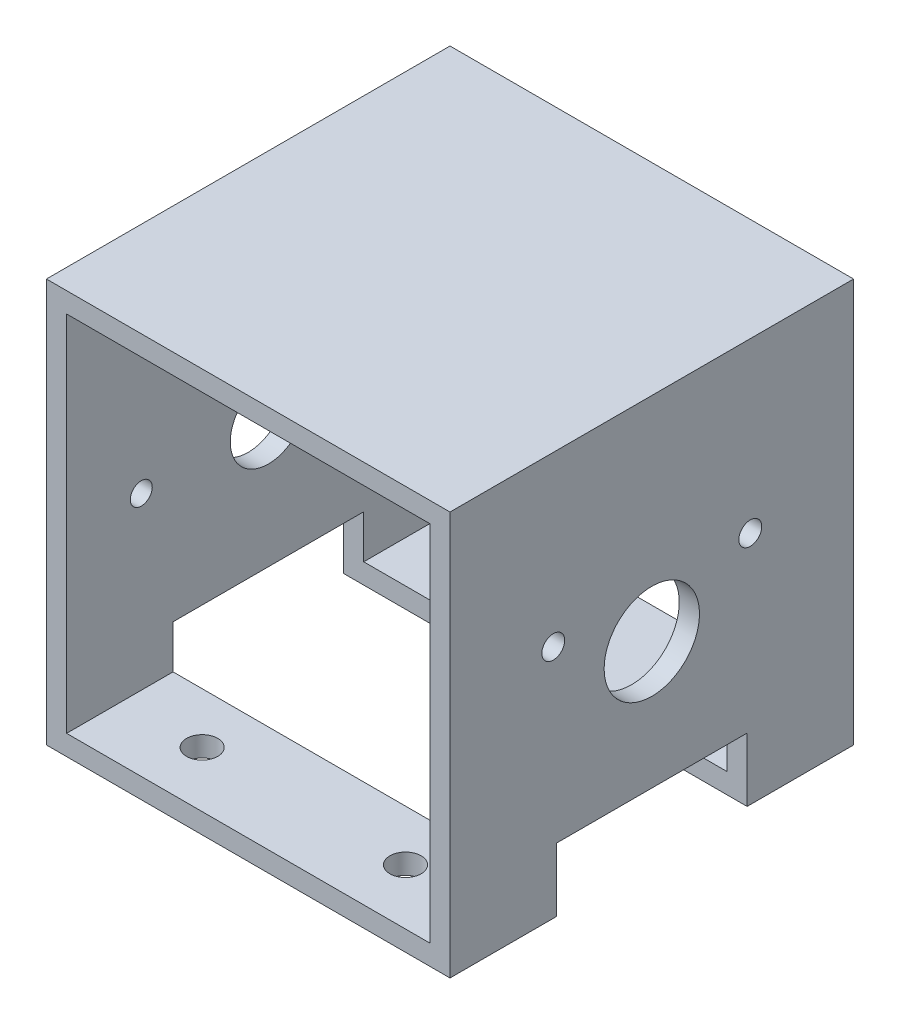
from build123d import *

# Parameters (mm, degrees)
SKETCH1_W                 = 63.5
SKETCH1_H                 = 63.5
SKETCH1_W_2               = 57.15
SKETCH1_H_2               = 57.15
EXTRUDE_THIN1_DEPTH       = 63.5
SKETCH2_W                 = 30
SKETCH2_H                 = 20
CUT_EXTRUDE1_DEPTH        = 64.5
SKETCH5_R                 = 7.5
CUT_EXTRUDE3_DEPTH        = 4.175
M3_CLEARANCE_HOLE1_D      = 3.6
M3_CLEARANCE_HOLE1_DEPTH  = 3.175
F_8_32_TAPPED_HOLE1_D     = 3.4544
F_8_32_TAPPED_HOLE1_DEPTH = 3.175
CUT_EXTRUDE4_REACH        = 65.5
SKETCH13_R                = 6
F_8_CLEARANCE_HOLE1_D     = 4.9149
F_8_CLEARANCE_HOLE1_DEPTH = 3.175


with BuildPart() as part:
    # Sketch1 → Extrude-Thin1 (new body)
    with BuildSketch(Plane.XY):
        Rectangle(SKETCH1_W, SKETCH1_H)
        Rectangle(SKETCH1_W_2, SKETCH1_H_2, mode=Mode.SUBTRACT)
    extrude(amount=EXTRUDE_THIN1_DEPTH)

    # Sketch2 → Cut-Extrude1 (cut, through all)
    with BuildSketch(Plane(origin=(31.75, 0, 0), x_dir=(0, 0, -1), z_dir=(1, 0, 0))):
        with Locations((-31.75, -31.75)):
            Rectangle(SKETCH2_W, SKETCH2_H)
    extrude(amount=-CUT_EXTRUDE1_DEPTH, mode=Mode.SUBTRACT)

    # Sketch5 → Cut-Extrude3 (cut, through all)
    with BuildSketch(Plane(origin=(28.575, 11.830115966, 29.988402314), x_dir=(0, 0, 1), z_dir=(-1, 0, 0))):
        with Locations((1.761597686, -13.580115966)):
            Circle(SKETCH5_R)
    extrude(amount=-CUT_EXTRUDE3_DEPTH, mode=Mode.SUBTRACT)

    # M3 Clearance Hole1
    with Locations(Plane(origin=(28.575, 11.830115966, 29.988402314), x_dir=(0, 0, 1), z_dir=(-1, 0, 0))):
        with Locations((-13.738402314, -6.580115966), (17.261597686, -6.580115966)):
            Hole(M3_CLEARANCE_HOLE1_D / 2, depth=M3_CLEARANCE_HOLE1_DEPTH)

    # #8-32 Tapped Hole1
    with Locations(Plane.ZY.offset(31.75)):
        with Locations((51.75, -1.75), (11.75, -1.75)):
            Hole(F_8_32_TAPPED_HOLE1_D / 2, depth=F_8_32_TAPPED_HOLE1_DEPTH)

    # Sketch13 → Cut-Extrude4 (cut, up to next)
    with BuildSketch(Plane.ZY.offset(31.75), mode=Mode.PRIVATE) as cut_extrude4_sk1:
        with Locations((31.75, -1.75)):
            Circle(SKETCH13_R)
    cut_extrude4_tool1 = extrude(cut_extrude4_sk1.sketch, amount=-CUT_EXTRUDE4_REACH, mode=Mode.PRIVATE) & part.part
    add(cut_extrude4_tool1.solids().sort_by_distance((-31.75, -1.75, 31.75))[0], mode=Mode.SUBTRACT)

    # #8 Clearance Hole1
    with Locations(Plane(origin=(0, -31.75, 0), x_dir=(-1, 0, 0), z_dir=(0, -1, 0))):
        with Locations((16, -8.75), (-16, -8.75), (-16, -54.75), (16, -54.75)):
            Hole(F_8_CLEARANCE_HOLE1_D / 2, depth=F_8_CLEARANCE_HOLE1_DEPTH)


solid = part.part
